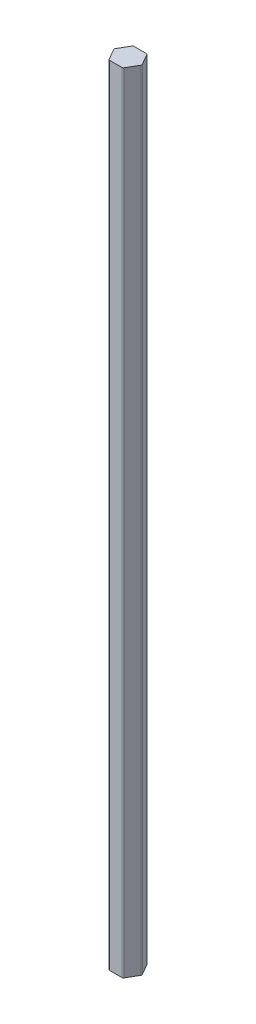
from build123d import *

# Parameters (mm, degrees)
EXTRUSION_DEPTH = 2860


with BuildPart() as part:
    # Esquisse2 → EXTRUSION (new body)
    with BuildSketch(Plane(origin=(0, 0, 0), x_dir=(1, 0, 0), z_dir=(0, 1, 0))):
        with BuildLine():
            Line((22.516660498, 44), (-22.516660498, 44))
            ThreePointArc((-22.516660498, 44), (-25.016660498, 43.330127019), (-26.846787517, 41.5))
            Line((-26.846787517, 41.5), (-49.363448016, 2.5))
            ThreePointArc((-49.363448016, 2.5), (-50.033320997, 0), (-49.363448016, -2.5))
            Line((-49.363448016, -2.5), (-26.846787517, -41.5))
            ThreePointArc((-26.846787517, -41.5), (-25.016660498, -43.330127019), (-22.516660498, -44))
            Line((-22.516660498, -44), (22.516660498, -44))
            ThreePointArc((22.516660498, -44), (25.016660498, -43.330127019), (26.846787517, -41.5))
            Line((26.846787517, -41.5), (49.363448016, -2.5))
            ThreePointArc((49.363448016, -2.5), (50.033320997, 0), (49.363448016, 2.5))
            Line((49.363448016, 2.5), (26.846787517, 41.5))
            ThreePointArc((26.846787517, 41.5), (25.016660498, 43.330127019), (22.516660498, 44))
        make_face()
    extrude(amount=EXTRUSION_DEPTH)


solid = part.part
